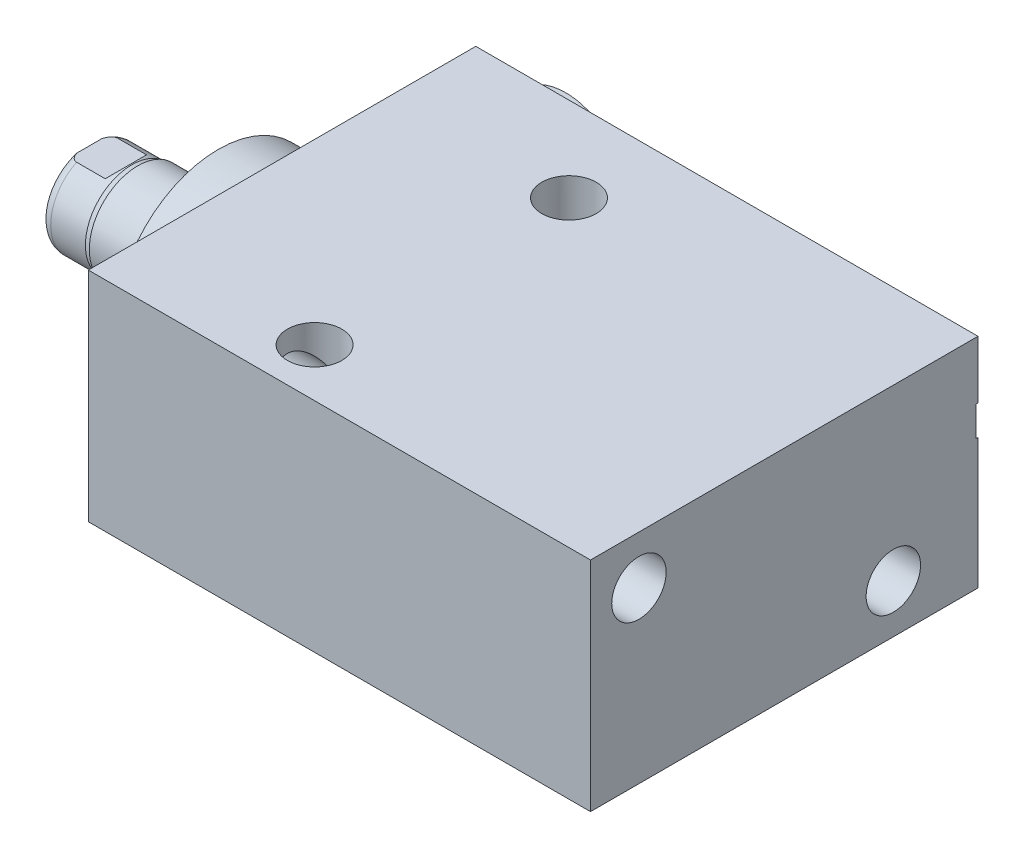
from build123d import *

# Parameters (mm, degrees)
SKETCH1_W          = 50.8
SKETCH1_H          = 28.575
EXTRUDE1_DEPTH     = 65.8368
SKETCH5_R          = 13.5001
EXTRUDE2_DEPTH     = 5.969
SKETCH6_W          = 6.35
SKETCH6_H          = 16.891
CUT_EXTRUDE4_DEPTH = 30.48
SKETCH13_R         = 7.874
EXTRUDE3_DEPTH     = 2.54
HOLE1_D            = 7.1374
HOLE1_DEPTH        = 65.8368
HOLE2_D            = 7.1374
HOLE2_DEPTH        = 28.575


with BuildPart() as part:
    # Sketch1 → Extrude1 (new body)
    with BuildSketch(Plane(origin=(0, 0, 0), x_dir=(0, 0, -1), z_dir=(1, 0, 0))):
        with Locations((2.3876, 0)):
            Rectangle(SKETCH1_W, SKETCH1_H)
    extrude(amount=EXTRUDE1_DEPTH)

    # S2D0002 → Cut-Revolve1 (revolve, cut)
    with BuildSketch(Plane(origin=(0, 4.7625, 0), x_dir=(-1, 0, 0), z_dir=(0, 1, 0)), mode=Mode.PRIVATE) as cut_revolve1_sk:
        Polygon((-15.7099, -27.5336), (-19.0499873, -27.5336), (-19.0499873, -27.7876), (-9.525, -27.7876), (-9.525, -13.5636), (-14.5034, -13.5636), (-14.5034, -24.316993135), (-15.167306865, -24.9809), align=None)
    revolve(cut_revolve1_sk.sketch.rotate(Axis((9.525, 4.7625, -19.13842003), (0, 0, 1)), 180), axis=Axis((9.525, 4.7625, -19.13842003), (0, 0, 1)), mode=Mode.SUBTRACT)  # turned: the seam where the file's is

    # Sketch3 → Cut-Revolve2 (revolve, cut)
    with BuildSketch(Plane(origin=(41.148, 4.7625, -25.146), x_dir=(1, 0, 0), z_dir=(0, 1, 0))):
        Polygon((21.5519, 2.3876), (24.8919873, 2.3876), (24.8919873, 2.6416), (15.367, 2.6416), (15.367, -11.5824), (20.3454, -11.5824), (20.3454, -0.829006865), (21.009306865, -0.1651), align=None)
    revolve(axis=Axis((56.515, 4.7625, -3.189624441), (0, 0, -1)), mode=Mode.SUBTRACT)

    # Sketch5 → Extrude2 (add)
    with BuildSketch(Plane.ZY):
        Circle(SKETCH5_R)
    extrude(amount=EXTRUDE2_DEPTH)

    # Sketch6 → Revolve1 (revolve)
    with BuildSketch(Plane(origin=(0, 0, 0), x_dir=(0, 0, 1), z_dir=(0, -1, 0)), mode=Mode.PRIVATE) as revolve1_sk:
        with Locations((-3.175, 14.4145)):
            Rectangle(SKETCH6_W, SKETCH6_H)
    revolve(revolve1_sk.sketch.rotate(Axis((5.754582971, 0, 0), (-1, 0, 0)), 180), axis=Axis((5.754582971, 0, 0), (-1, 0, 0)))  # turned: the seam where the file's is

    # S2D0001 → Cut-Revolve4 (revolve, cut)
    with BuildSketch(Plane(origin=(-18.511260017, 3.2639, 0), x_dir=(0, 1, 0), z_dir=(0, 0, 1)), mode=Mode.PRIVATE) as cut_revolve4_sk:
        Polygon((-0.7112, 2.786949769), (-0.7112, -11.653260017), (-3.2639, -13.18707692), (-3.2639, 4.348739983), (0.1905, 4.348739983), align=None)
    revolve(cut_revolve4_sk.sketch.rotate(Axis((0, 0, 0), (-1, 0, 0)), 90), axis=Axis((0, 0, 0), (-1, 0, 0)), mode=Mode.SUBTRACT)  # turned: the seam where the file's is

    # Sketch8 → Cut-Revolve5 (revolve, cut)
    with BuildSketch(Plane(origin=(0, 0, 0), x_dir=(0, 0, -1), z_dir=(0, 1, 0)), mode=Mode.PRIVATE) as cut_revolve5_sk:
        with BuildLine():
            Line((-6.35, 16.5354), (-6.096, 17.2974))
            Line((-6.096, 17.2974), (-6.096, 21.844))
            ThreePointArc((-6.096, 21.844), (-5.995678675, 22.387796865), (-5.707922533, 22.86))
            Line((-5.707922533, 22.86), (-6.35, 22.86))
            Line((-6.35, 22.86), (-6.35, 16.5354))
        make_face()
    revolve(cut_revolve5_sk.sketch.rotate(Axis((-12.65936, 0, 0), (-1, 0, 0)), 180), axis=Axis((-12.65936, 0, 0), (-1, 0, 0)), mode=Mode.SUBTRACT)  # turned: the seam where the file's is

    # Sketch12 → Cut-Extrude4 (cut, symmetric)
    with BuildSketch(Plane(origin=(0, 0, 0), x_dir=(0, -1, 0), z_dir=(0, 0, -1))):
        Polygon((5.461, 22.86), (5.461, 18.0848), (6.096, 17.4498), (6.096, 22.86), align=None)
        Polygon((-5.461, 22.86), (-5.461, 18.0848), (-6.096, 17.4498), (-6.096, 22.86), align=None)
    extrude(amount=CUT_EXTRUDE4_DEPTH, both=True, mode=Mode.SUBTRACT)

    # Sketch13 → Extrude3 (add)
    with BuildSketch(Plane(origin=(0, 0, -27.5336), x_dir=(-1, 0, 0), z_dir=(0, 0, -1))):
        with Locations((-9.525, 4.7625)):
            Circle(SKETCH13_R)
    extrude(amount=EXTRUDE3_DEPTH)

    # Hole1
    with Locations(Plane.ZY):
        with Locations((-16.6878, -7.9248), (16.6624, 7.9502)):
            Hole(HOLE1_D / 2, depth=HOLE1_DEPTH)

    # Hole2
    with Locations(Plane(origin=(0, 14.2875, 0), x_dir=(-1, 0, 0), z_dir=(0, 1, 0))):
        with Locations((-23.3172, -16.6878), (-23.3172, 16.6624)):
            Hole(HOLE2_D / 2, depth=HOLE2_DEPTH)


solid = part.part
